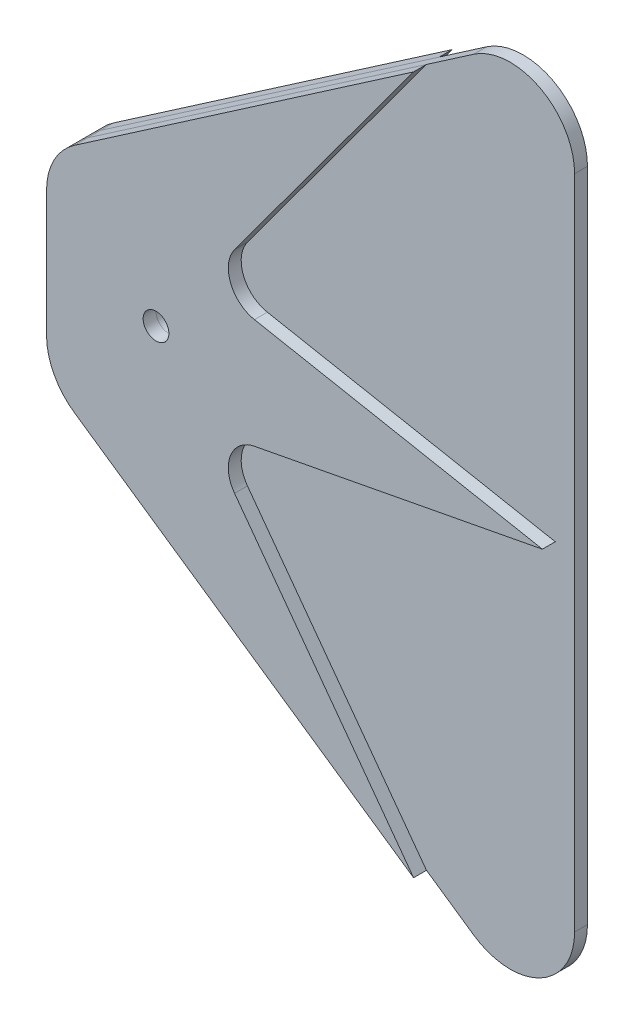
from build123d import *

# Parameters (mm, degrees)
SKETCH1_R           = 2
BOSS_EXTRUDE1_DEPTH = 1
SKETCH2_R           = 2
BOSS_EXTRUDE2_DEPTH = 2


with BuildPart() as part:
    # Sketch1 → Boss-Extrude1 (new body, symmetric)
    with BuildSketch(Plane.XY):
        with BuildLine():
            Line((-17, 9.739695101), (-17, -9.739695101))
            ThreePointArc((-17, -9.739695101), (-15.850222661, -14.395182063), (-12.665288229, -17.980114343))
            Line((-12.665288229, -17.980114343), (47.334711771, -59.230114343))
            ThreePointArc((47.334711771, -59.230114343), (57.655486962, -59.839917761), (63, -50.989695101))
            Line((63, -50.989695101), (63, 50.989695101))
            ThreePointArc((63, 50.989695101), (57.655486962, 59.839917761), (47.334711771, 59.230114343))
            Line((47.334711771, 59.230114343), (-12.665288229, 17.980114343))
            ThreePointArc((-12.665288229, 17.980114343), (-15.850222661, 14.395182063), (-17, 9.739695101))
        make_face()
        Circle(SKETCH1_R, mode=Mode.SUBTRACT)
    extrude(amount=BOSS_EXTRUDE1_DEPTH, both=True)


with BuildPart() as body_2:
    # Sketch2 → Boss-Extrude2 (new body)
    with BuildSketch(Plane.XY.offset(1)):
        with BuildLine():
            Line((-17, 9.739695101), (-17, -9.739695101))
            ThreePointArc((-17, -9.739695101), (-15.850222661, -14.395182063), (-12.665288229, -17.980114343))
            Line((-12.665288229, -17.980114343), (40, -54.1875))
            Line((40, -54.1875), (12.199838689, -16.389972987))
            ThreePointArc((12.199838689, -16.389972987), (11.573707783, -11.599797128), (15.292133323, -8.515784129))
            Line((15.292133323, -8.515784129), (60, 0))
            Line((60, 0), (15.292133323, 8.515784129))
            ThreePointArc((15.292133323, 8.515784129), (11.573707783, 11.599797128), (12.199838689, 16.389972987))
            Line((12.199838689, 16.389972987), (40, 54.1875))
            Line((40, 54.1875), (-12.665288229, 17.980114343))
            ThreePointArc((-12.665288229, 17.980114343), (-15.850222661, 14.395182063), (-17, 9.739695101))
        make_face()
        Circle(SKETCH2_R, mode=Mode.SUBTRACT)
    extrude(amount=BOSS_EXTRUDE2_DEPTH)


with BuildPart() as body_3:
    # Mirror1: mirrored copy
    add(body_2.part.mirror(Plane.XY))


solid = Compound([part.part, body_2.part, body_3.part])
